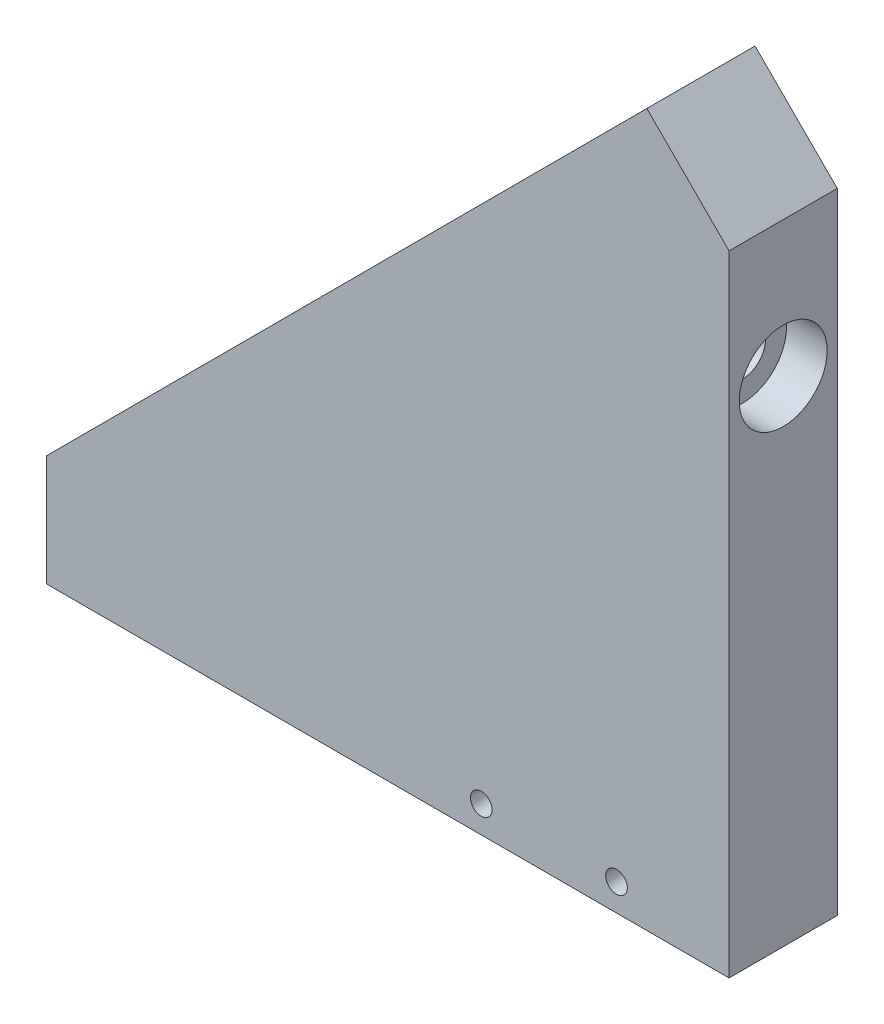
from build123d import *

# Parameters (mm, degrees)
BOSS_EXTRUDE1_DEPTH            = 4
SKETCH3_W                      = 59.68
SKETCH3_H                      = 8
BOSS_EXTRUDE2_DEPTH            = 5.46
SKETCH5_W                      = 2.16
SKETCH5_H                      = 59.704316385
CUT_EXTRUDE2_DEPTH             = 9
CUT_EXTRUDE3_DEPTH             = 9
CBORE_FOR_M3_SHCS2_D           = 3.4
CBORE_FOR_M3_SHCS2_CBORE_D     = 6.5
CBORE_FOR_M3_SHCS2_CBORE_DEPTH = 3
M2X0_4_TAPPED_HOLE1_D          = 1.6
M2X0_4_TAPPED_HOLE1_DEPTH      = 7
M2X0_4_TAPPED_HOLE1_TIP        = 0.480688495
CUT_EXTRUDE4_DEPTH             = 9
SKETCH22_R                     = 1.5
CUT_EXTRUDE6_DEPTH             = 5.5
M3X0_5_TAPPED_HOLE2_D          = 2.5
M3X0_5_TAPPED_HOLE2_DEPTH      = 8.5
M3X0_5_TAPPED_HOLE2_TIP        = 0.751075774


with BuildPart() as part:
    # Sketch2 → Boss-Extrude1 (new body, symmetric)
    with BuildSketch(Plane.XY):
        Polygon((-8.360559535, 17.409242356), (51.319440465, 17.409242356), (51.319440465, 71.653558741), (36.009440465, 71.653558741), (43.084036895, 64.586021309), (-1.285963105, 20.171704924), (-8.360559535, 27.239242356), align=None)
    extrude(amount=BOSS_EXTRUDE1_DEPTH, both=True)

    # Sketch3 → Boss-Extrude2 (add)
    with BuildSketch(Plane.XZ.offset(-17.409242356)):
        with Locations((21.479440465, 0)):
            Rectangle(SKETCH3_W, SKETCH3_H)
    extrude(amount=BOSS_EXTRUDE2_DEPTH)

    # Sketch5 → Cut-Extrude2 (cut, through all)
    with BuildSketch(Plane.XY.offset(4)):
        with Locations((50.239440465, 41.801400548)):
            Rectangle(SKETCH5_W, SKETCH5_H)
    extrude(amount=-CUT_EXTRUDE2_DEPTH, mode=Mode.SUBTRACT)

    # Sketch9 → Cut-Extrude3 (cut, through all)
    with BuildSketch(Plane.XY.offset(4)):
        Polygon((36.009440465, 71.653558741), (49.159440465, 58.503558741), (49.159440465, 71.653558741), align=None)
    extrude(amount=-CUT_EXTRUDE3_DEPTH, mode=Mode.SUBTRACT)

    # CBORE for M3 SHCS2 (through all)
    with Locations(Plane(origin=(49.159440465, 0, 0), x_dir=(0, 0, -1), z_dir=(1, 0, 0))):
        with Locations((0, 48.503558741)):
            CounterBoreHole(CBORE_FOR_M3_SHCS2_D / 2, CBORE_FOR_M3_SHCS2_CBORE_D / 2, CBORE_FOR_M3_SHCS2_CBORE_DEPTH)

    # M2x0.4 Tapped Hole1
    with Locations(Plane.XY.offset(4)):
        with Locations((30.839440465, 13.949242356), (40.839440465, 13.949242356)):
            Hole(M2X0_4_TAPPED_HOLE1_D / 2, depth=M2X0_4_TAPPED_HOLE1_DEPTH)
            with Locations((0, 0, -(M2X0_4_TAPPED_HOLE1_DEPTH + M2X0_4_TAPPED_HOLE1_TIP / 2))):  # 118° drill point
                Cone(0, M2X0_4_TAPPED_HOLE1_D / 2, M2X0_4_TAPPED_HOLE1_TIP, mode=Mode.SUBTRACT)

    # Sketch20 → Cut-Extrude4 (cut, through all)
    with BuildSketch(Plane.XY.offset(4)):
        Polygon((-1.285963105, 20.171704924), (-1.285963105, 11.949242356), (-8.360559535, 11.949242356), (-8.360559535, 27.239242356), align=None)
    extrude(amount=-CUT_EXTRUDE4_DEPTH, mode=Mode.SUBTRACT)

    # Sketch22 → Cut-Extrude6 (cut)
    with BuildSketch(Plane(origin=(-10.729470873, 10.71876506, 0), x_dir=(0, 0, 1), z_dir=(-0.707459643, 0.706753743, 0))):
        with Locations((0, 23.361807925)):
            Circle(SKETCH22_R)
    extrude(amount=-CUT_EXTRUDE6_DEPTH, mode=Mode.SUBTRACT)

    # M3x0.5 Tapped Hole2
    with Locations(Plane.ZY.offset(1.285963105)):
        with Locations((0, 15.949242356)):
            Hole(M3X0_5_TAPPED_HOLE2_D / 2, depth=M3X0_5_TAPPED_HOLE2_DEPTH)
            with Locations((0, 0, -(M3X0_5_TAPPED_HOLE2_DEPTH + M3X0_5_TAPPED_HOLE2_TIP / 2))):  # 118° drill point
                Cone(0, M3X0_5_TAPPED_HOLE2_D / 2, M3X0_5_TAPPED_HOLE2_TIP, mode=Mode.SUBTRACT)


solid = part.part
